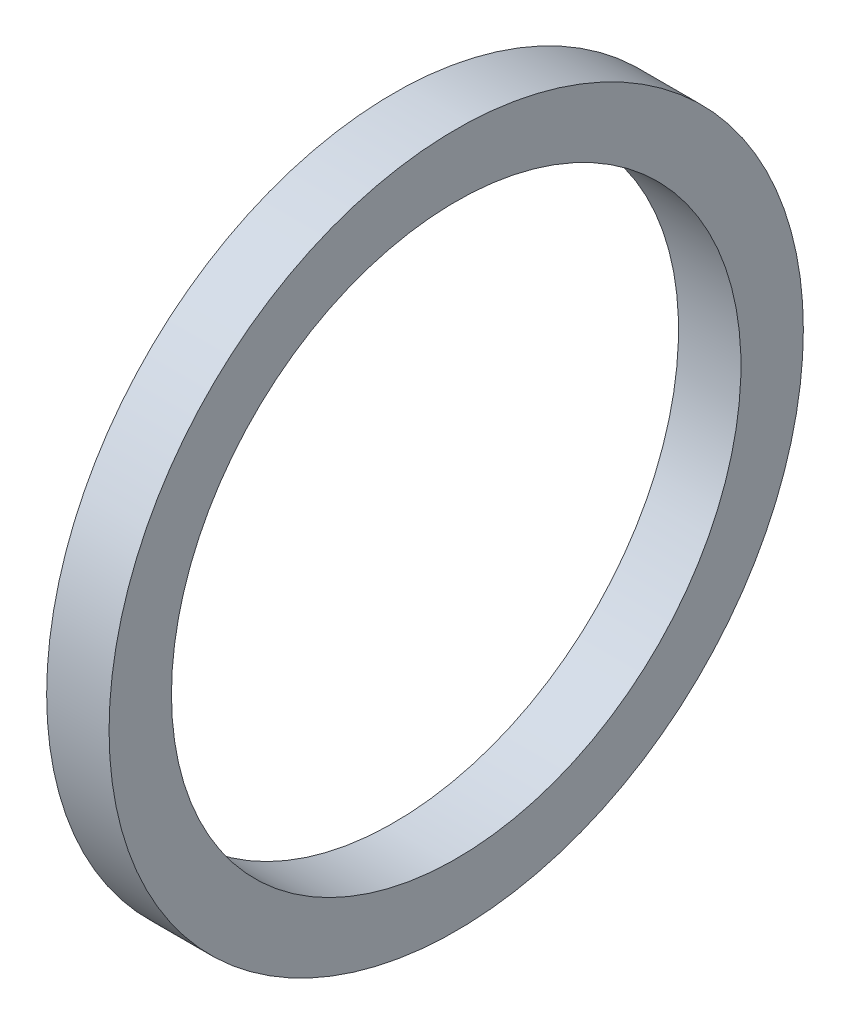
from build123d import *

# Parameters (mm, degrees)
SKETCH1_W = 2.032
SKETCH1_H = 2.032


with BuildPart() as part:
    # Sketch1 → Revolve1 (revolve)
    with BuildSketch(Plane.XY, mode=Mode.PRIVATE) as revolve1_sk:
        with Locations((1.016, -10.287)):
            Rectangle(SKETCH1_W, SKETCH1_H)
    revolve(revolve1_sk.sketch.rotate(Axis((-43.716580756, 0, 0), (1, 0, 0)), 270), axis=Axis((-43.716580756, 0, 0), (1, 0, 0)))  # turned: the seam where the file's is


solid = part.part
